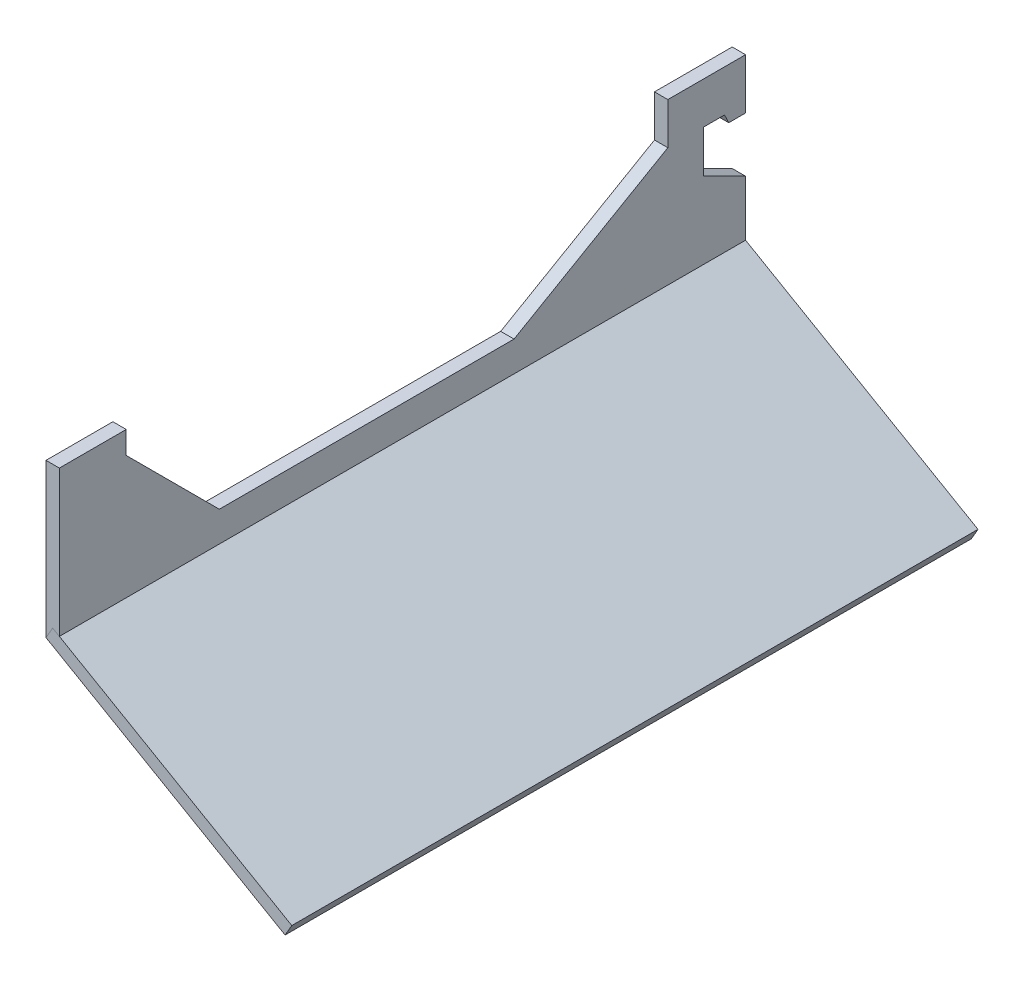
from build123d import *

# Parameters (mm, degrees)
BOSS_EXTRUDE1_DEPTH = 3.175
SKETCH11_W          = 163
SKETCH11_H          = 65.580816733
BOSS_EXTRUDE2_DEPTH = 3.175


with BuildPart() as part:
    # Sketch10 → Boss-Extrude1 (new body)
    with BuildSketch(Plane(origin=(0, 0, 0), x_dir=(0, 0, -1), z_dir=(1, 0, 0))):
        Polygon((15.884918301, 36.464807754), (0, 36.464807754), (0, 0), (163, 0), (163, 15), (153, 20), (153, 30.093444916), (158, 30.093444916), (159, 28), (163, 28), (163, 40), (153, 40), (144.534918301, 40), (144.534918301, 36.464807754), (144.534918301, 30.093444916), (108, 9), (38, 9), (15.884918301, 31.115081699), align=None)
    extrude(amount=BOSS_EXTRUDE1_DEPTH)


with BuildPart() as body_2:
    # Sketch11 → Boss-Extrude2 (new body)
    with BuildSketch(Plane(origin=(0, 0, 0), x_dir=(0, 0, -1), z_dir=(-0.5, -0.866025404, 0))):
        with Locations((81.5, 32.790408367)):
            Rectangle(SKETCH11_W, SKETCH11_H)
    extrude(amount=-BOSS_EXTRUDE2_DEPTH)


solid = Compound([part.part, body_2.part])
